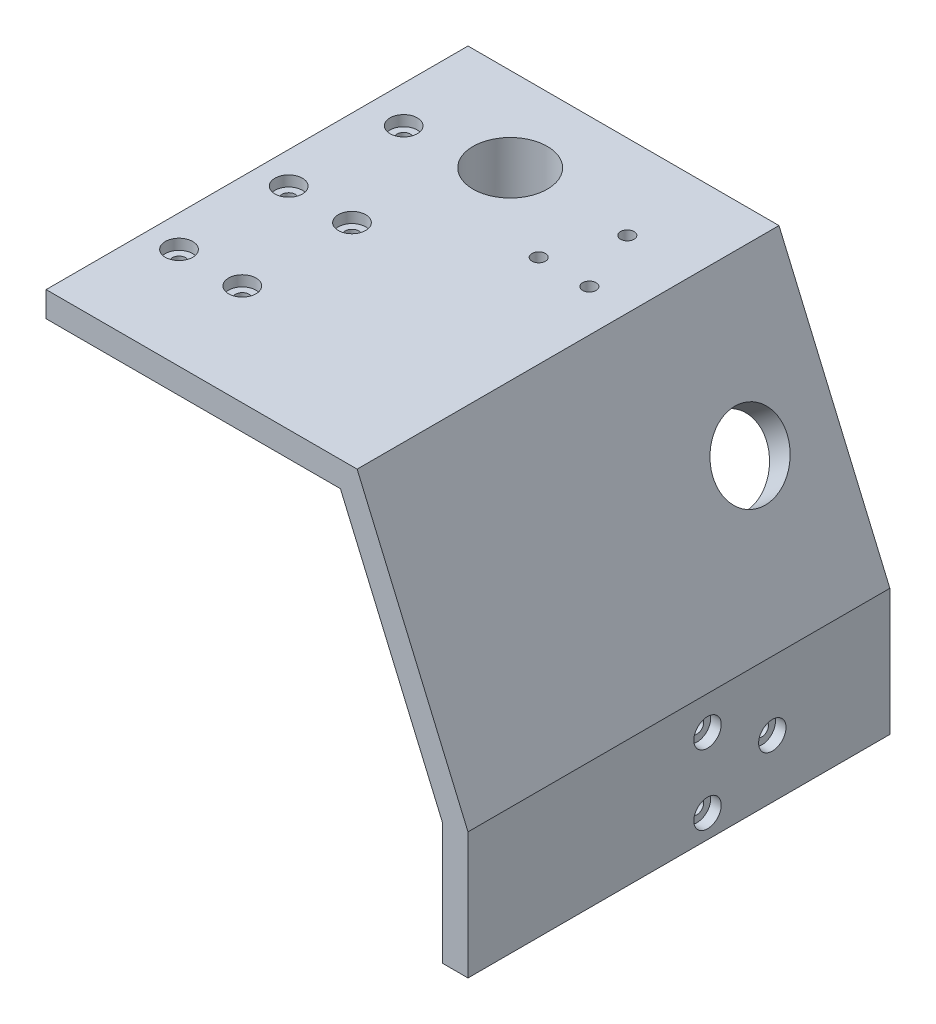
from build123d import *

# Parameters (mm, degrees)
SALIENTE_EXTRUIR1_DEPTH = 100
CORTAR_EXTRUIR1_REACH   = 170.346
CROQUIS3_R              = 8.8
CORTAR_EXTRUIR2_REACH   = 226.945
CROQUIS4_R              = 8.8
CORTAR_EXTRUIR3_DEPTH   = 0.5
CORTAR_EXTRUIR4_REACH   = 241.691
CROQUIS6_R              = 1.6
CROQUIS7_R              = 3.25
CORTAR_EXTRUIR5_DEPTH   = 2.5
CROQUIS8_W              = 75
CROQUIS8_H              = 12
CROQUIS8_W_2            = 35
CORTAR_EXTRUIR6_DEPTH   = 2.5
CORTAR_EXTRUIR7_REACH   = 168.473
CROQUIS9_R              = 1.6
CROQUIS10_R             = 3.25
CORTAR_EXTRUIR8_DEPTH   = 2.5
CROQUIS11_R             = 10.3
CROQUIS11_R_2           = 8.8
SALIENTE_EXTRUIR2_DEPTH = 10
SALIENTE_EXTRUIR3_REACH = 201.802
CROQUIS12_R             = 10.3
CROQUIS12_R_2           = 8.8
CORTAR_EXTRUIR9_REACH   = 167.168
CROQUIS13_R             = 1.6
CROQUIS14_W             = 100
CROQUIS14_H             = 100
CORTAR_EXTRUIR10_DEPTH  = 169.345575526


with BuildPart() as part:
    # Croquis1 → Saliente-Extruir1 (new body)
    with BuildSketch(Plane.XY):
        Polygon((-100, 25), (-100, -5), (-94, -5), (-94, 23.768453788), (-69.761533754, 80.324875029), (69.761533754, 80.324875029), (94, 23.768453788), (94, -5), (100, -5), (100, 25), (73.717910702, 86.324875029), (-73.717910702, 86.324875029), align=None)
    extrude(amount=SALIENTE_EXTRUIR1_DEPTH)

    # Croquis3 → Cortar-Extruir1 (cut, up to next)
    with BuildSketch(Plane(origin=(0, 86.324875029, 0), x_dir=(1, 0, 0), z_dir=(0, 1, 0)), mode=Mode.PRIVATE) as cortar_extruir1_sk1:
        with Locations(Location((-30, -20, 0), (0, 0, 270))):
            Circle(CROQUIS3_R)
    cortar_extruir1_tool1 = extrude(cortar_extruir1_sk1.sketch, amount=-CORTAR_EXTRUIR1_REACH, mode=Mode.PRIVATE) & part.part
    # Croquis3 → Cortar-Extruir1 (cut, up to next)
    with BuildSketch(Plane(origin=(0, 86.324875029, 0), x_dir=(1, 0, 0), z_dir=(0, 1, 0)), mode=Mode.PRIVATE) as cortar_extruir1_sk2:
        with Locations(Location((30, -20, 0), (0, 0, 270))):
            Circle(CROQUIS3_R)
    cortar_extruir1_tool2 = extrude(cortar_extruir1_sk2.sketch, amount=-CORTAR_EXTRUIR1_REACH, mode=Mode.PRIVATE) & part.part
    add(cortar_extruir1_tool1.solids().sort_by_distance((-30, 86.324875, 20))[0], mode=Mode.SUBTRACT)
    add(cortar_extruir1_tool2.solids().sort_by_distance((30, 86.324875, 20))[0], mode=Mode.SUBTRACT)

    # Cortar-Extruir2: up to this plane
    cortar_extruir2_end = Plane(origin=(-94, 23.768453788, 100), z_dir=(-0.9191450300180581, 0.3939192985791672, 0))
    # Croquis4 → Cortar-Extruir2 (cut, up to the surface)
    with BuildSketch(Plane(origin=(-87.479517168, 68.836107355, 0), x_dir=(0, 0, -1), z_dir=(-0.7858721058939679, 0.6183890629512945, 0)), mode=Mode.PRIVATE) as cortar_extruir2_sk1:
        with Locations(Location((-20, 9.96907102, 0), (0, 0, 270))):
            Circle(CROQUIS4_R)
    cortar_extruir2_tool1 = split(extrude(cortar_extruir2_sk1.sketch, amount=-CORTAR_EXTRUIR2_REACH, mode=Mode.PRIVATE), bisect_by=cortar_extruir2_end, keep=Keep.BOTH, mode=Mode.PRIVATE)
    cortar_extruir2 = cortar_extruir2_tool1.solids().sort_by_distance((-93.644282, 61.001693, 20))[0]
    add(cortar_extruir2, mode=Mode.SUBTRACT)

    # Simetría1: Cortar-Extruir2 across plane
    add(cortar_extruir2.mirror(Plane(origin=(0, 0, 0), x_dir=(0, 0, 1), z_dir=(1, 0, 0))), mode=Mode.SUBTRACT)

    # Croquis5 → Cortar-Extruir3 (cut)
    with BuildSketch(Plane.XZ.offset(-80.324875029)):
        with BuildLine():
            Line((14.875, 0), (15.175, 0))
            Line((15.175, 0), (15.175, 2.3))
            Line((15.175, 2.3), (3.784177586, 2.3))
            ThreePointArc((3.784177586, 2.3), (0, 3.1), (-3.784177586, 2.3))
            Line((-3.784177586, 2.3), (-15.175, 2.3))
            Line((-15.175, 2.3), (-15.175, 0))
            Line((-15.175, 0), (-14.875, 0))
            Line((-14.875, 0), (-14.875, 2))
            Line((-14.875, 2), (-3.720215048, 2))
            ThreePointArc((-3.720215048, 2), (0, 2.8), (3.720215048, 2))
            Line((3.720215048, 2), (14.875, 2))
            Line((14.875, 2), (14.875, 0))
        make_face()
        with BuildLine():
            Line((3.261901286, 0), (14.875, 0))
            Line((14.875, 0), (14.875, 2))
            Line((14.875, 2), (3.720215048, 2))
            ThreePointArc((3.720215048, 2), (0, 2.8), (-3.720215048, 2))
            Line((-3.720215048, 2), (-14.875, 2))
            Line((-14.875, 2), (-14.875, 0))
            Line((-14.875, 0), (-3.261901286, 0))
            ThreePointArc((-3.261901286, 0), (0, 0.8), (3.261901286, 0))
        make_face()
        with BuildLine():
            Line((-3.261901286, 0), (3.261901286, 0))
            ThreePointArc((3.261901286, 0), (0, 0.8), (-3.261901286, 0))
        make_face()
    extrude(amount=-CORTAR_EXTRUIR3_DEPTH, mode=Mode.SUBTRACT)

    # Croquis6 → Cortar-Extruir4 (cut, up to next)
    with BuildSketch(Plane.ZY.offset(100), mode=Mode.PRIVATE) as cortar_extruir4_sk1:
        with Locations(Location((43.227046774, 0.497681725, 0), (0, 0, 270))):
            Circle(CROQUIS6_R)
    cortar_extruir4_tool1 = extrude(cortar_extruir4_sk1.sketch, amount=-CORTAR_EXTRUIR4_REACH, mode=Mode.PRIVATE) & part.part
    # Croquis6 → Cortar-Extruir4 (cut, up to next)
    with BuildSketch(Plane.ZY.offset(100), mode=Mode.PRIVATE) as cortar_extruir4_sk2:
        with Locations(Location((27.863523387, 8.768453788, 0), (0, 0, 270))):
            Circle(CROQUIS6_R)
    cortar_extruir4_tool2 = extrude(cortar_extruir4_sk2.sketch, amount=-CORTAR_EXTRUIR4_REACH, mode=Mode.PRIVATE) & part.part
    # Croquis6 → Cortar-Extruir4 (cut, up to next)
    with BuildSketch(Plane.ZY.offset(100), mode=Mode.PRIVATE) as cortar_extruir4_sk3:
        with Locations(Location((43.227046774, 17.039225851, 0), (0, 0, 270))):
            Circle(CROQUIS6_R)
    cortar_extruir4_tool3 = extrude(cortar_extruir4_sk3.sketch, amount=-CORTAR_EXTRUIR4_REACH, mode=Mode.PRIVATE) & part.part
    cortar_extruir4_1 = cortar_extruir4_tool1.solids().sort_by_distance((-100, 0.497682, 43.227047))[0]
    add(cortar_extruir4_1, mode=Mode.SUBTRACT)
    cortar_extruir4_2 = cortar_extruir4_tool2.solids().sort_by_distance((-100, 8.768454, 27.863523))[0]
    add(cortar_extruir4_2, mode=Mode.SUBTRACT)
    cortar_extruir4_3 = cortar_extruir4_tool3.solids().sort_by_distance((-100, 17.039226, 43.227047))[0]
    add(cortar_extruir4_3, mode=Mode.SUBTRACT)
    cortar_extruir4 = cortar_extruir4_1 + cortar_extruir4_2 + cortar_extruir4_3  # Cortar-Extruir4 as one shape, for the pattern or mirror that repeats it

    # Croquis7 → Cortar-Extruir5 (cut)
    with BuildSketch(Plane.ZY.offset(100)):
        with Locations(Location((27.863523387, 8.768453788, 0), (0, 0, 270))):
            Circle(CROQUIS7_R)
        with Locations(Location((43.227046774, 0.497681725, 0), (0, 0, 270))):
            Circle(CROQUIS7_R)
        with Locations(Location((43.227046774, 17.039225851, 0), (0, 0, 270))):
            Circle(CROQUIS7_R)
    cortar_extruir5 = extrude(amount=-CORTAR_EXTRUIR5_DEPTH, mode=Mode.SUBTRACT)

    # Simetría2: Cortar-Extruir4, Cortar-Extruir5 across plane
    add(cortar_extruir4.mirror(Plane(origin=(0, 0, 0), x_dir=(0, 0, 1), z_dir=(1, 0, 0))), mode=Mode.SUBTRACT)
    add(cortar_extruir5.mirror(Plane(origin=(0, 0, 0), x_dir=(0, 0, 1), z_dir=(1, 0, 0))), mode=Mode.SUBTRACT)

    # Croquis8 → Cortar-Extruir6 (cut)
    with BuildSketch(Plane.XZ.offset(-80.324875029)):
        with Locations((0, 76)):
            Rectangle(CROQUIS8_W, CROQUIS8_H)
        with Locations((0, 50)):
            Rectangle(CROQUIS8_W, CROQUIS8_H)
        with Locations((0, 24)):
            Rectangle(CROQUIS8_W_2, CROQUIS8_H)
    extrude(amount=-CORTAR_EXTRUIR6_DEPTH, mode=Mode.SUBTRACT)

    # Croquis9 → Cortar-Extruir7 (cut, up to next)
    with BuildSketch(Plane.XZ.offset(-82.824875029), mode=Mode.PRIVATE) as cortar_extruir7_sk1:
        with Locations(Location((-22.5, 76, 0), (0, 0, 270))):
            Circle(CROQUIS9_R)
    cortar_extruir7_tool1 = extrude(cortar_extruir7_sk1.sketch, amount=-CORTAR_EXTRUIR7_REACH, mode=Mode.PRIVATE) & part.part
    # Croquis9 → Cortar-Extruir7 (cut, up to next)
    with BuildSketch(Plane.XZ.offset(-82.824875029), mode=Mode.PRIVATE) as cortar_extruir7_sk2:
        with Locations(Location((-7.5, 76, 0), (0, 0, 270))):
            Circle(CROQUIS9_R)
    cortar_extruir7_tool2 = extrude(cortar_extruir7_sk2.sketch, amount=-CORTAR_EXTRUIR7_REACH, mode=Mode.PRIVATE) & part.part
    # Croquis9 → Cortar-Extruir7 (cut, up to next)
    with BuildSketch(Plane.XZ.offset(-82.824875029), mode=Mode.PRIVATE) as cortar_extruir7_sk3:
        with Locations(Location((7.5, 76, 0), (0, 0, 270))):
            Circle(CROQUIS9_R)
    cortar_extruir7_tool3 = extrude(cortar_extruir7_sk3.sketch, amount=-CORTAR_EXTRUIR7_REACH, mode=Mode.PRIVATE) & part.part
    # Croquis9 → Cortar-Extruir7 (cut, up to next)
    with BuildSketch(Plane.XZ.offset(-82.824875029), mode=Mode.PRIVATE) as cortar_extruir7_sk4:
        with Locations(Location((22.5, 76, 0), (0, 0, 270))):
            Circle(CROQUIS9_R)
    cortar_extruir7_tool4 = extrude(cortar_extruir7_sk4.sketch, amount=-CORTAR_EXTRUIR7_REACH, mode=Mode.PRIVATE) & part.part
    # Croquis9 → Cortar-Extruir7 (cut, up to next)
    with BuildSketch(Plane.XZ.offset(-82.824875029), mode=Mode.PRIVATE) as cortar_extruir7_sk5:
        with Locations(Location((-22.5, 50, 0), (0, 0, 270))):
            Circle(CROQUIS9_R)
    cortar_extruir7_tool5 = extrude(cortar_extruir7_sk5.sketch, amount=-CORTAR_EXTRUIR7_REACH, mode=Mode.PRIVATE) & part.part
    # Croquis9 → Cortar-Extruir7 (cut, up to next)
    with BuildSketch(Plane.XZ.offset(-82.824875029), mode=Mode.PRIVATE) as cortar_extruir7_sk6:
        with Locations(Location((-7.5, 50, 0), (0, 0, 270))):
            Circle(CROQUIS9_R)
    cortar_extruir7_tool6 = extrude(cortar_extruir7_sk6.sketch, amount=-CORTAR_EXTRUIR7_REACH, mode=Mode.PRIVATE) & part.part
    # Croquis9 → Cortar-Extruir7 (cut, up to next)
    with BuildSketch(Plane.XZ.offset(-82.824875029), mode=Mode.PRIVATE) as cortar_extruir7_sk7:
        with Locations(Location((7.5, 50, 0), (0, 0, 270))):
            Circle(CROQUIS9_R)
    cortar_extruir7_tool7 = extrude(cortar_extruir7_sk7.sketch, amount=-CORTAR_EXTRUIR7_REACH, mode=Mode.PRIVATE) & part.part
    # Croquis9 → Cortar-Extruir7 (cut, up to next)
    with BuildSketch(Plane.XZ.offset(-82.824875029), mode=Mode.PRIVATE) as cortar_extruir7_sk8:
        with Locations(Location((22.5, 50, 0), (0, 0, 270))):
            Circle(CROQUIS9_R)
    cortar_extruir7_tool8 = extrude(cortar_extruir7_sk8.sketch, amount=-CORTAR_EXTRUIR7_REACH, mode=Mode.PRIVATE) & part.part
    # Croquis9 → Cortar-Extruir7 (cut, up to next)
    with BuildSketch(Plane.XZ.offset(-82.824875029), mode=Mode.PRIVATE) as cortar_extruir7_sk9:
        with Locations(Location((-8.75, 24, 0), (0, 0, 270))):
            Circle(CROQUIS9_R)
    cortar_extruir7_tool9 = extrude(cortar_extruir7_sk9.sketch, amount=-CORTAR_EXTRUIR7_REACH, mode=Mode.PRIVATE) & part.part
    # Croquis9 → Cortar-Extruir7 (cut, up to next)
    with BuildSketch(Plane.XZ.offset(-82.824875029), mode=Mode.PRIVATE) as cortar_extruir7_sk10:
        with Locations(Location((8.75, 24, 0), (0, 0, 270))):
            Circle(CROQUIS9_R)
    cortar_extruir7_tool10 = extrude(cortar_extruir7_sk10.sketch, amount=-CORTAR_EXTRUIR7_REACH, mode=Mode.PRIVATE) & part.part
    add(cortar_extruir7_tool1.solids().sort_by_distance((-22.5, 82.824875, 76))[0], mode=Mode.SUBTRACT)
    add(cortar_extruir7_tool2.solids().sort_by_distance((-7.5, 82.824875, 76))[0], mode=Mode.SUBTRACT)
    add(cortar_extruir7_tool3.solids().sort_by_distance((7.5, 82.824875, 76))[0], mode=Mode.SUBTRACT)
    add(cortar_extruir7_tool4.solids().sort_by_distance((22.5, 82.824875, 76))[0], mode=Mode.SUBTRACT)
    add(cortar_extruir7_tool5.solids().sort_by_distance((-22.5, 82.824875, 50))[0], mode=Mode.SUBTRACT)
    add(cortar_extruir7_tool6.solids().sort_by_distance((-7.5, 82.824875, 50))[0], mode=Mode.SUBTRACT)
    add(cortar_extruir7_tool7.solids().sort_by_distance((7.5, 82.824875, 50))[0], mode=Mode.SUBTRACT)
    add(cortar_extruir7_tool8.solids().sort_by_distance((22.5, 82.824875, 50))[0], mode=Mode.SUBTRACT)
    add(cortar_extruir7_tool9.solids().sort_by_distance((-8.75, 82.824875, 24))[0], mode=Mode.SUBTRACT)
    add(cortar_extruir7_tool10.solids().sort_by_distance((8.75, 82.824875, 24))[0], mode=Mode.SUBTRACT)

    # Croquis10 → Cortar-Extruir8 (cut)
    with BuildSketch(Plane(origin=(0, 86.324875029, 0), x_dir=(1, 0, 0), z_dir=(0, 1, 0))):
        with Locations(Location((-22.5, -50, 0), (0, 0, 270))):
            Circle(CROQUIS10_R)
        with Locations(Location((-7.5, -50, 0), (0, 0, 270))):
            Circle(CROQUIS10_R)
        with Locations(Location((7.5, -50, 0), (0, 0, 270))):
            Circle(CROQUIS10_R)
        with Locations(Location((22.5, -50, 0), (0, 0, 270))):
            Circle(CROQUIS10_R)
        with Locations(Location((8.75, -24, 0), (0, 0, 270))):
            Circle(CROQUIS10_R)
        with Locations(Location((-8.75, -24, 0), (0, 0, 270))):
            Circle(CROQUIS10_R)
        with Locations(Location((22.5, -76, 0), (0, 0, 270))):
            Circle(CROQUIS10_R)
        with Locations(Location((7.5, -76, 0), (0, 0, 270))):
            Circle(CROQUIS10_R)
        with Locations(Location((-7.5, -76, 0), (0, 0, 270))):
            Circle(CROQUIS10_R)
        with Locations(Location((-22.5, -76, 0), (0, 0, 270))):
            Circle(CROQUIS10_R)
    extrude(amount=-CORTAR_EXTRUIR8_DEPTH, mode=Mode.SUBTRACT)

    # Croquis11 → Saliente-Extruir2 (add)
    with BuildSketch(Plane.XZ.offset(-80.324875029)):
        with Locations(Location((-30, 20, 0), (0, 0, 90))):
            Circle(CROQUIS11_R)
        with Locations(Location((-30, 20, 0), (0, 0, 90))):
            Circle(CROQUIS11_R_2, mode=Mode.SUBTRACT)
        with Locations(Location((30, 20, 0), (0, 0, 90))):
            Circle(CROQUIS11_R)
        with Locations(Location((30, 20, 0), (0, 0, 90))):
            Circle(CROQUIS11_R_2, mode=Mode.SUBTRACT)
    extrude(amount=SALIENTE_EXTRUIR2_DEPTH)

    # Saliente-Extruir3: up to this plane
    saliente_extruir3_end = Plane(origin=(-94, 23.768453788, 100), z_dir=(-0.9191450300180581, 0.3939192985791672, 0))
    # Croquis12 → Saliente-Extruir3 (add, up to the surface)
    with BuildSketch(Plane(origin=(-63.903353991, 50.284435467, 0), x_dir=(0, 0, -1), z_dir=(-0.7858721058939679, 0.6183890629512945, 0)), mode=Mode.PRIVATE) as saliente_extruir3_sk1:
        with Locations(Location((-20, 9.96907102, 0), (0, 0, 90))):
            Circle(CROQUIS12_R)
        with Locations(Location((-20, 9.96907102, 0), (0, 0, 90))):
            Circle(CROQUIS12_R_2, mode=Mode.SUBTRACT)
    saliente_extruir3_tool1 = split(extrude(saliente_extruir3_sk1.sketch, amount=SALIENTE_EXTRUIR3_REACH, mode=Mode.PRIVATE), bisect_by=saliente_extruir3_end, keep=Keep.BOTH, mode=Mode.PRIVATE)
    add(saliente_extruir3_tool1.solids().sort_by_distance((-63.878865, 50.315557, 20))[0])

    # Croquis13 → Cortar-Extruir9 (cut, up to next)
    with BuildSketch(Plane.XZ.offset(-80.324875029), mode=Mode.PRIVATE) as cortar_extruir9_sk1:
        with Locations(Location((57.761533754, 20, 0), (0, 0, 270))):
            Circle(CROQUIS13_R)
    cortar_extruir9_tool1 = extrude(cortar_extruir9_sk1.sketch, amount=-CORTAR_EXTRUIR9_REACH, mode=Mode.PRIVATE) & part.part
    # Croquis13 → Cortar-Extruir9 (cut, up to next)
    with BuildSketch(Plane.XZ.offset(-80.324875029), mode=Mode.PRIVATE) as cortar_extruir9_sk2:
        with Locations(Location((51.761533754, 35, 0), (0, 0, 270))):
            Circle(CROQUIS13_R)
    cortar_extruir9_tool2 = extrude(cortar_extruir9_sk2.sketch, amount=-CORTAR_EXTRUIR9_REACH, mode=Mode.PRIVATE) & part.part
    # Croquis13 → Cortar-Extruir9 (cut, up to next)
    with BuildSketch(Plane.XZ.offset(-80.324875029), mode=Mode.PRIVATE) as cortar_extruir9_sk3:
        with Locations(Location((63.761533754, 35, 0), (0, 0, 270))):
            Circle(CROQUIS13_R)
    cortar_extruir9_tool3 = extrude(cortar_extruir9_sk3.sketch, amount=-CORTAR_EXTRUIR9_REACH, mode=Mode.PRIVATE) & part.part
    # Croquis13 → Cortar-Extruir9 (cut, up to next)
    with BuildSketch(Plane.XZ.offset(-80.324875029), mode=Mode.PRIVATE) as cortar_extruir9_sk4:
        with Locations(Location((-57.761533754, 20, 0), (0, 0, 270))):
            Circle(CROQUIS13_R)
    cortar_extruir9_tool4 = extrude(cortar_extruir9_sk4.sketch, amount=-CORTAR_EXTRUIR9_REACH, mode=Mode.PRIVATE) & part.part
    # Croquis13 → Cortar-Extruir9 (cut, up to next)
    with BuildSketch(Plane.XZ.offset(-80.324875029), mode=Mode.PRIVATE) as cortar_extruir9_sk5:
        with Locations(Location((-63.761533754, 35, 0), (0, 0, 270))):
            Circle(CROQUIS13_R)
    cortar_extruir9_tool5 = extrude(cortar_extruir9_sk5.sketch, amount=-CORTAR_EXTRUIR9_REACH, mode=Mode.PRIVATE) & part.part
    # Croquis13 → Cortar-Extruir9 (cut, up to next)
    with BuildSketch(Plane.XZ.offset(-80.324875029), mode=Mode.PRIVATE) as cortar_extruir9_sk6:
        with Locations(Location((-51.761533754, 35, 0), (0, 0, 270))):
            Circle(CROQUIS13_R)
    cortar_extruir9_tool6 = extrude(cortar_extruir9_sk6.sketch, amount=-CORTAR_EXTRUIR9_REACH, mode=Mode.PRIVATE) & part.part
    add(cortar_extruir9_tool1.solids().sort_by_distance((57.761534, 80.324875, 20))[0], mode=Mode.SUBTRACT)
    add(cortar_extruir9_tool2.solids().sort_by_distance((51.761534, 80.324875, 35))[0], mode=Mode.SUBTRACT)
    add(cortar_extruir9_tool3.solids().sort_by_distance((63.761534, 80.324875, 35))[0], mode=Mode.SUBTRACT)
    add(cortar_extruir9_tool4.solids().sort_by_distance((-57.761534, 80.324875, 20))[0], mode=Mode.SUBTRACT)
    add(cortar_extruir9_tool5.solids().sort_by_distance((-63.761534, 80.324875, 35))[0], mode=Mode.SUBTRACT)
    add(cortar_extruir9_tool6.solids().sort_by_distance((-51.761534, 80.324875, 35))[0], mode=Mode.SUBTRACT)

    # Croquis14 → Cortar-Extruir10 (cut, through all)
    with BuildSketch(Plane(origin=(0, 86.324875029, 0), x_dir=(1, 0, 0), z_dir=(0, 1, 0))):
        with Locations((-50, -50)):
            Rectangle(CROQUIS14_W, CROQUIS14_H)
    extrude(amount=-CORTAR_EXTRUIR10_DEPTH, mode=Mode.SUBTRACT)


solid = part.part
